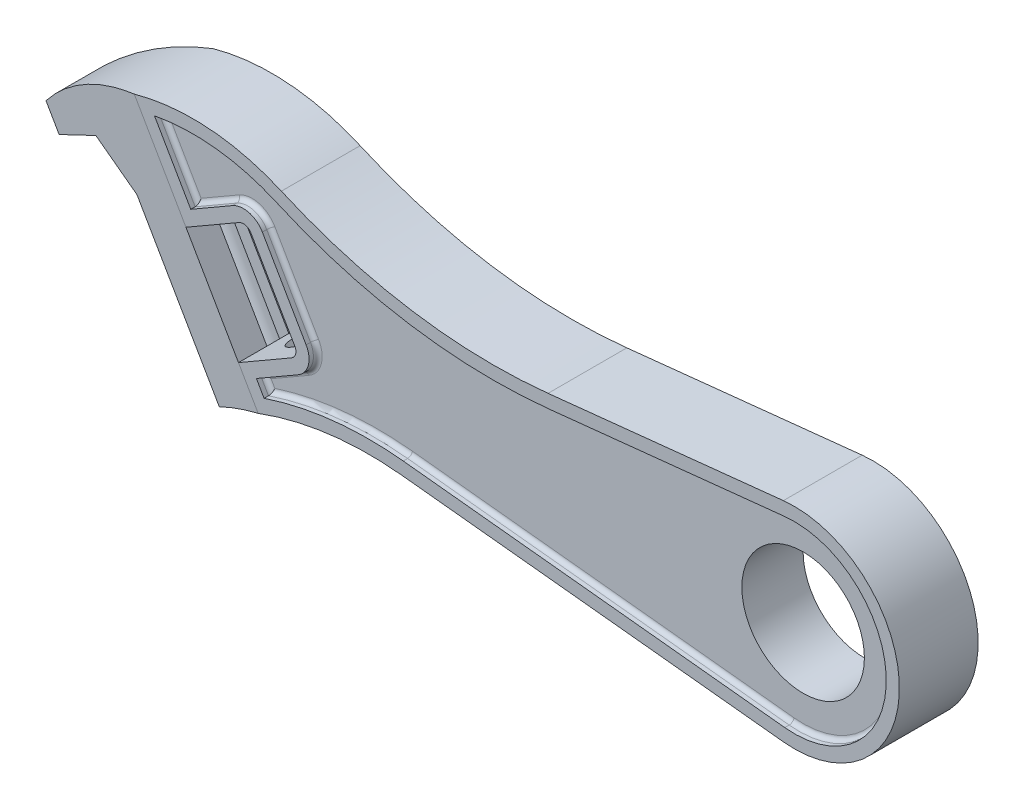
from build123d import *

# Parameters (mm, degrees)
SKETCH1_R               = 7
BOSS_EXTRUDE1_DEPTH     = 9
CUT_EXTRUDE1_DEPTH      = 83.87446055
CUT_EXTRUDE1_DEPTH_BACK = 4
SKETCH2_R               = 2
CUT_EXTRUDE2_START      = -8
CUT_EXTRUDE2_DEPTH      = 8
CUT_EXTRUDE3_DEPTH      = 84.772444126
CUT_EXTRUDE3_DEPTH_BACK = 84.772444126
FILLET1_R               = 1
CUT_EXTRUDE6_DEPTH      = 1
FILLET2_R               = 0.5
FILLET2_OF_MIRROR1_R    = 0.5


with BuildPart() as part:
    # Sketch1 → Boss-Extrude1 (new body)
    with BuildSketch(Plane.XY):
        with BuildLine():
            Line((-44.842954804, -7.352914883), (-1.254341216, -11.934262781))
            ThreePointArc((-1.254341216, -11.934262781), (12, 0), (-1.254341216, 11.934262781))
            Line((-1.254341216, 11.934262781), (-28.139253345, 9.108544651))
            ThreePointArc((-28.139253345, 9.108544651), (-43.686422074, 9.501145293), (-58.610412286, 13.876428933))
            ThreePointArc((-58.610412286, 13.876428933), (-74.481071491, 15.320859611), (-88, 6.882685902))
            Line((-88, 6.882685902), (-86.5, 4.284609691))
            Line((-86.5, 4.284609691), (-81.303847577, 7.284609691))
            Line((-81.303847577, 7.284609691), (-76.107695155, 4.284609691))
            Line((-76.107695155, 4.284609691), (-66.705771366, -12))
            ThreePointArc((-66.705771366, -12), (-56.142376072, -7.945092459), (-44.842954804, -7.352914883))
        make_face()
        Polygon((-56.581415713, -1.535898385), (-63.509618943, -5.535898385), (-69.509618943, 4.856406461), (-62.581415713, 8.856406461), align=None, mode=Mode.SUBTRACT)
        Circle(SKETCH1_R, mode=Mode.SUBTRACT)
    extrude(amount=BOSS_EXTRUDE1_DEPTH)

    # Sketch2 → Cut-Extrude1 (cut, two sides: drawn at the far end of the back side and taken through both)
    with BuildSketch(Plane(origin=(-19.480290419, 33.740852752, 0), x_dir=(0.8660254037844365, 0.5000000000000039, 0), z_dir=(0.5000000000000038, -0.8660254037844364, 0)).offset(-CUT_EXTRUDE1_DEPTH_BACK)):
        with BuildLine():
            Line((-59.207643082, 3.25), (-57.768892582, 3.25))
            Line((-57.768892582, 3.25), (-57.768892582, 5.75))
            Line((-57.768892582, 5.75), (-59.207643082, 5.75))
            ThreePointArc((-59.207643082, 5.75), (-60.768892582, 6.5), (-62.330142082, 5.75))
            Line((-62.330142082, 5.75), (-68.08829873, 5.75))
            Line((-68.08829873, 5.75), (-68.08829873, 3.25))
            Line((-68.08829873, 3.25), (-62.330142082, 3.25))
            ThreePointArc((-62.330142082, 3.25), (-60.768892582, 2.5), (-59.207643082, 3.25))
        make_face()
        with Locations((-53.768892582, 4.5)):
            Circle(SKETCH2_R)
    extrude(amount=CUT_EXTRUDE1_DEPTH + CUT_EXTRUDE1_DEPTH_BACK, mode=Mode.SUBTRACT)

    # Sketch2_4 → Cut-Extrude2 (cut)
    with BuildSketch(Plane(origin=(-19.480290419, 33.740852752, 0), x_dir=(0.8660254037844365, 0.5000000000000039, 0), z_dir=(0.5000000000000038, -0.8660254037844364, 0)).offset(CUT_EXTRUDE2_START)):
        with BuildLine():
            Line((-59.207643082, 3.25), (-57.768892582, 3.25))
            Line((-57.768892582, 3.25), (-57.768892582, 5.75))
            Line((-57.768892582, 5.75), (-59.207643082, 5.75))
            ThreePointArc((-59.207643082, 5.75), (-60.768892582, 6.5), (-62.330142082, 5.75))
            Line((-62.330142082, 5.75), (-68.08829873, 5.75))
            Line((-68.08829873, 5.75), (-68.08829873, 3.25))
            Line((-68.08829873, 3.25), (-62.330142082, 3.25))
            ThreePointArc((-62.330142082, 3.25), (-60.768892582, 2.5), (-59.207643082, 3.25))
        make_face()
    extrude(amount=CUT_EXTRUDE2_DEPTH, mode=Mode.SUBTRACT)

    # Sketch3 → Cut-Extrude3 (cut, two sides: drawn at the far end of the back side and taken through both)
    with BuildSketch(Plane(origin=(-23.480290419, 40.669055982, 0), x_dir=(0.8660254037844364, 0.5000000000000041, 0), z_dir=(0.5000000000000041, -0.8660254037844364, 0)).offset(-CUT_EXTRUDE3_DEPTH_BACK)):
        Polygon((-57.768892582, 9), (-72.768892582, 9), (-72.768892582, 6.5), align=None)
        Polygon((-57.768892582, 0), (-72.768892582, 2.5), (-72.768892582, 0), align=None)
    extrude(amount=CUT_EXTRUDE3_DEPTH + CUT_EXTRUDE3_DEPTH_BACK, mode=Mode.SUBTRACT)

    # Fillet1
    fillet1_edges = [part.edges().sort_by_distance(p)[0] for p in [
        (-56.581415713, -1.535898385, 4.5),
        (-62.581415713, 8.856406461, 4.5),
    ]]
    fillet(fillet1_edges, radius=FILLET1_R)

    # Sketch5 → Cut-Extrude6 (cut)
    with BuildSketch(Plane.XY.offset(9)):
        with BuildLine():
            Line((-61.460580838, -6.084936491), (-60.58344819, -7.6041748))
            ThreePointArc((-60.58344819, -7.6041748), (-52.728383532, -5.879179053), (-44.686162109, -5.86113204))
            Line((-44.686162109, -5.86113204), (-1.097548864, -10.442479901))
            ThreePointArc((-1.097548864, -10.442479901), (10.5, 0), (-1.097548864, 10.442479901))
            Line((-1.097548864, 10.442479901), (-27.98246065, 7.616761808))
            ThreePointArc((-27.98246065, 7.616761808), (-43.918308598, 8.019177466), (-59.215398565, 12.503843197))
            ThreePointArc((-59.215398565, 12.503843197), (-66.039706904, 14.349674352), (-73.104183378, 14.082374693))
            Line((-73.104183378, 14.082374693), (-68.960580838, 6.905444566))
            Line((-68.960580838, 6.905444566), (-64.197441117, 9.655444566))
            ThreePointArc((-64.197441117, 9.655444566), (-62.300393504, 9.905195622), (-60.782377607, 8.740381057))
            Line((-60.782377607, 8.740381057), (-55.782377607, 0.080127019))
            ThreePointArc((-55.782377607, 0.080127019), (-55.532626551, -1.816920594), (-56.697441117, -3.334936491))
            Line((-56.697441117, -3.334936491), (-61.460580838, -6.084936491))
        make_face()
    cut_extrude6 = extrude(amount=-CUT_EXTRUDE6_DEPTH, mode=Mode.SUBTRACT)

    # Fillet2
    fillet2_edges = [part.edges().sort_by_distance(p)[0] for p in [
        (-55.532626551, -1.816920594, 8),
        (-58.282377607, 4.410254038, 8),
        (-62.300393504, 9.905195622, 8),
        (-66.579010977, 8.280444566, 8),
        (-71.032382108, 10.49390963, 8),
        (-66.039706904, 14.349674352, 8),
        (-14.540004757, 9.029620855, 8),
        (10.5, 0, 8),
        (-22.891855486, -8.151805971, 8),
        (-52.728383532, -5.879179053, 8),
        (-59.079010977, -4.709936491, 8),
        (-43.918308598, 8.019177466, 8),
        (-61.022014514, -6.844555645, 8),
    ]]
    fillet(fillet2_edges, radius=FILLET2_R)

    # Mirror1: Cut-Extrude6 across plane
    add(cut_extrude6.mirror(Plane.XY.offset(4.5)), mode=Mode.SUBTRACT)

    # Fillet2 of Mirror1
    fillet2_of_mirror1_edges = [part.edges().sort_by_distance(p)[0] for p in [
        (-55.532626551, -1.816920594, 1),
        (-58.282377607, 4.410254038, 1),
        (-62.300393504, 9.905195622, 1),
        (-66.579010977, 8.280444566, 1),
        (-71.032382108, 10.49390963, 1),
        (-66.039706904, 14.349674352, 1),
        (-14.540004757, 9.029620855, 1),
        (10.5, 0, 1),
        (-22.891855486, -8.151805971, 1),
        (-52.728383532, -5.879179053, 1),
        (-59.079010977, -4.709936491, 1),
        (-43.918308598, 8.019177466, 1),
        (-61.022014514, -6.844555645, 1),
    ]]
    fillet(fillet2_of_mirror1_edges, radius=FILLET2_OF_MIRROR1_R)


solid = part.part
